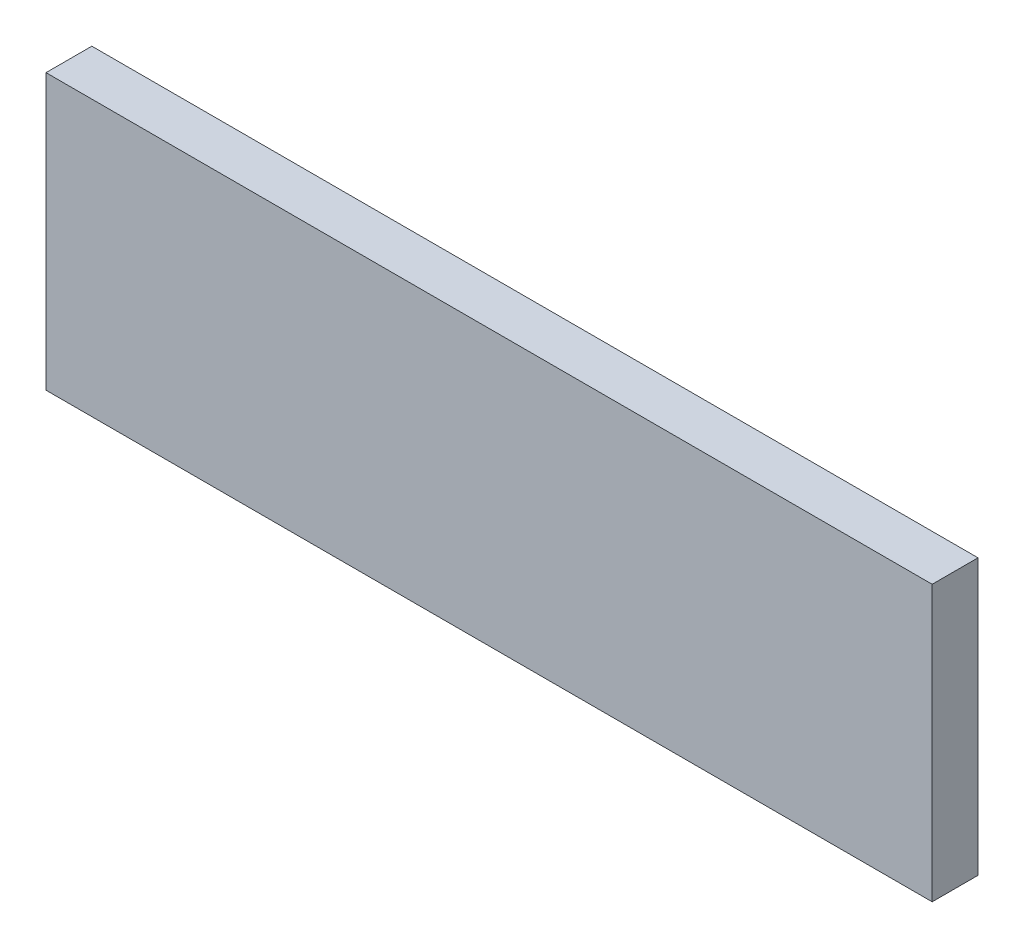
from build123d import *

# Parameters (mm, degrees)
SKETCH1_W           = 19.05
SKETCH1_H           = 114.3
BOSS_EXTRUDE1_DEPTH = 368.3


with BuildPart() as part:
    # Sketch1 → Boss-Extrude1 (new body)
    with BuildSketch(Plane(origin=(0, 0, 0), x_dir=(0, 0, -1), z_dir=(1, 0, 0))):
        Rectangle(SKETCH1_W, SKETCH1_H)
    extrude(amount=BOSS_EXTRUDE1_DEPTH)


solid = part.part
